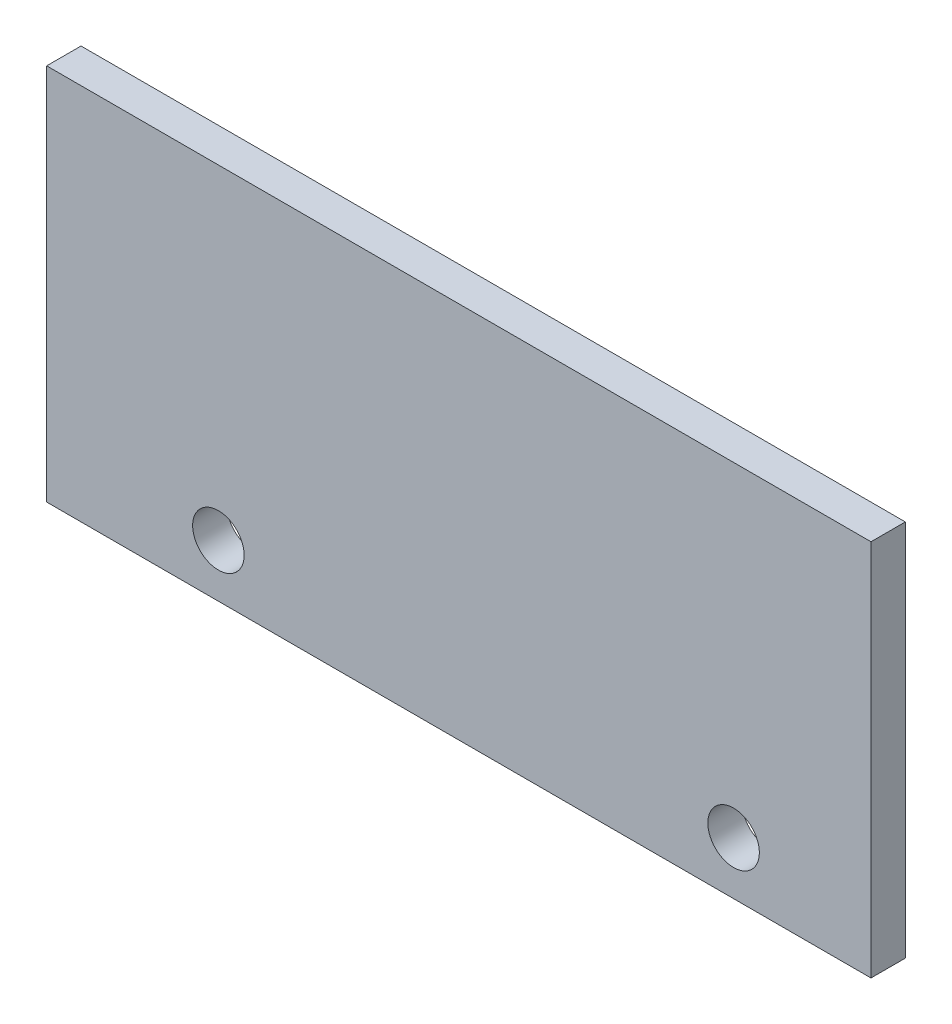
from build123d import *

# Parameters (mm, degrees)
SKETCH1_W          = 152.4
SKETCH1_H          = 69.85
EXTRUDE1_DEPTH     = 6.35
SKETCH2_R          = 4.7625
CUT_EXTRUDE1_DEPTH = 7.35


with BuildPart() as part:
    # Sketch1 → Extrude1 (new body)
    with BuildSketch(Plane.XY):
        with Locations((749.3, 295.275)):
            Rectangle(SKETCH1_W, SKETCH1_H)
    extrude(amount=EXTRUDE1_DEPTH)

    # Sketch2 → Cut-Extrude1 (cut, through all)
    with BuildSketch(Plane.XY.offset(6.35)):
        with Locations((800.1, 270.09725)):
            Circle(SKETCH2_R)
        with Locations((704.85, 270.09725)):
            Circle(SKETCH2_R)
    extrude(amount=-CUT_EXTRUDE1_DEPTH, mode=Mode.SUBTRACT)


solid = part.part
